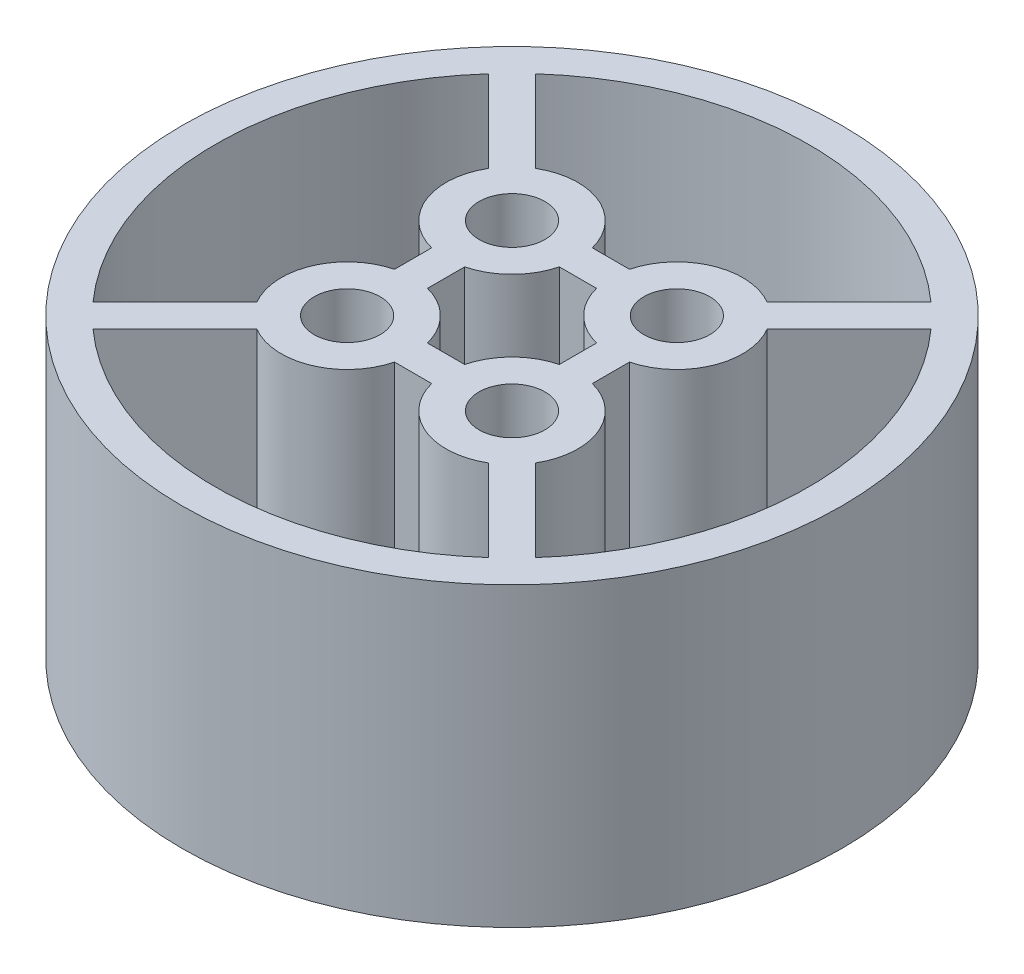
from build123d import *

# Parameters (mm, degrees)
SKETCH_2_R      = 20
SKETCH_2_R_2    = 2
EXTRUDE_1_DEPTH = 18


with BuildPart() as part:
    # 草图2 → 凸台-拉伸1 (new body)
    with BuildSketch(Plane(origin=(0, 0, 0), x_dir=(1, 0, 0), z_dir=(0, 1, 0))):
        Circle(SKETCH_2_R)
        with Locations((-5, 5)):
            Circle(SKETCH_2_R_2, mode=Mode.SUBTRACT)
        with Locations((5, 5)):
            Circle(SKETCH_2_R_2, mode=Mode.SUBTRACT)
        with Locations((5, -5)):
            Circle(SKETCH_2_R_2, mode=Mode.SUBTRACT)
        with Locations((-5, -5)):
            Circle(SKETCH_2_R_2, mode=Mode.SUBTRACT)
        with BuildLine():
            Line((-8.445719569, 7.031506006), (-13.415371808, 12.001158246))
            ThreePointArc((-13.415371808, 12.001158246), (-18, 0), (-13.415371808, -12.001158246))
            Line((-13.415371808, -12.001158246), (-8.445719569, -7.031506006))
            ThreePointArc((-8.445719569, -7.031506006), (-8.69551813, -3.469266271), (-6, -1.127016654))
            Line((-6, -1.127016654), (-6, 1.127016654))
            ThreePointArc((-6, 1.127016654), (-8.69551813, 3.469266271), (-8.445719569, 7.031506006))
        make_face(mode=Mode.SUBTRACT)
        with BuildLine():
            Line((-12.001158246, 13.415371808), (-7.031506006, 8.445719569))
            ThreePointArc((-7.031506006, 8.445719569), (-3.469266271, 8.69551813), (-1.127016654, 6))
            Line((-1.127016654, 6), (1.127016654, 6))
            ThreePointArc((1.127016654, 6), (3.469266271, 8.69551813), (7.031506006, 8.445719569))
            Line((7.031506006, 8.445719569), (12.001158246, 13.415371808))
            ThreePointArc((12.001158246, 13.415371808), (0, 18), (-12.001158246, 13.415371808))
        make_face(mode=Mode.SUBTRACT)
        with BuildLine():
            Line((13.415371808, 12.001158246), (8.445719569, 7.031506006))
            ThreePointArc((8.445719569, 7.031506006), (8.69551813, 3.469266271), (6, 1.127016654))
            Line((6, 1.127016654), (6, -1.127016654))
            ThreePointArc((6, -1.127016654), (8.69551813, -3.469266271), (8.445719569, -7.031506006))
            Line((8.445719569, -7.031506006), (13.415371808, -12.001158246))
            ThreePointArc((13.415371808, -12.001158246), (18, 0), (13.415371808, 12.001158246))
        make_face(mode=Mode.SUBTRACT)
        with BuildLine():
            Line((12.001158246, -13.415371808), (7.031506006, -8.445719569))
            ThreePointArc((7.031506006, -8.445719569), (3.469266271, -8.69551813), (1.127016654, -6))
            Line((1.127016654, -6), (-1.127016654, -6))
            ThreePointArc((-1.127016654, -6), (-3.469266271, -8.69551813), (-7.031506006, -8.445719569))
            Line((-7.031506006, -8.445719569), (-12.001158246, -13.415371808))
            ThreePointArc((-12.001158246, -13.415371808), (0, -18), (12.001158246, -13.415371808))
        make_face(mode=Mode.SUBTRACT)
        with BuildLine():
            Line((-1.127016654, 4), (1.127016654, 4))
            ThreePointArc((1.127016654, 4), (2.171572875, 2.171572875), (4, 1.127016654))
            Line((4, 1.127016654), (4, -1.127016654))
            ThreePointArc((4, -1.127016654), (2.171572875, -2.171572875), (1.127016654, -4))
            Line((1.127016654, -4), (-1.127016654, -4))
            ThreePointArc((-1.127016654, -4), (-2.171572875, -2.171572875), (-4, -1.127016654))
            Line((-4, -1.127016654), (-4, 1.127016654))
            ThreePointArc((-4, 1.127016654), (-2.171572875, 2.171572875), (-1.127016654, 4))
        make_face(mode=Mode.SUBTRACT)
    extrude(amount=EXTRUDE_1_DEPTH)


solid = part.part
